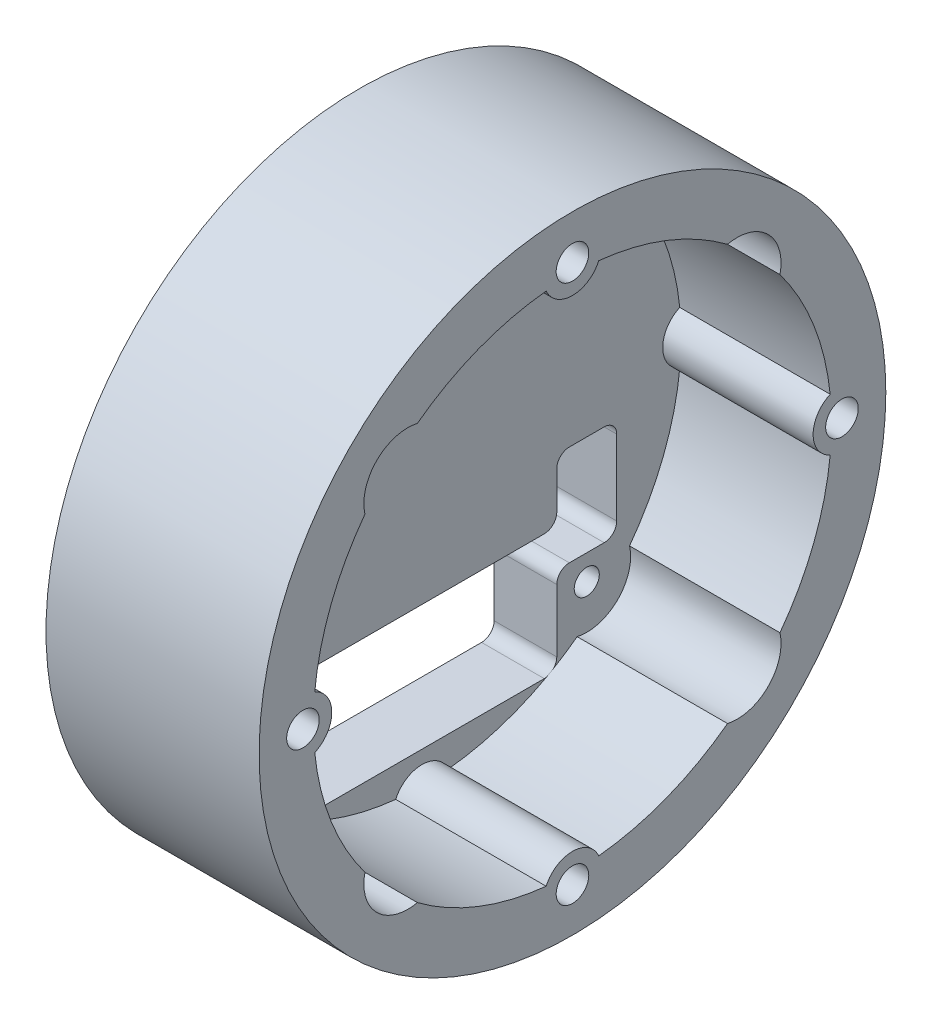
from build123d import *

# Parameters (mm, degrees)
SKETCH1_R               = 25
BOSS_EXTRUDE1_DEPTH     = 5
SKETCH3_R               = 1
CUT_EXTRUDE2_DEPTH      = 6
SKETCH4_R               = 25
SKETCH4_R_2             = 20.666666667
BOSS_EXTRUDE2_DEPTH     = 12
SKETCH2_R               = 1.3
CUT_EXTRUDE1_DEPTH      = 13
CUT_EXTRUDE1_DEPTH_BACK = 6
CUT_EXTRUDE3_DEPTH      = 6
CUT_EXTRUDE5_DEPTH      = 13
SKETCH8_R               = 2.3
SKETCH8_R_2             = 1.3
BOSS_EXTRUDE3_DEPTH     = 12


with BuildPart() as part:
    # Sketch1 → Boss-Extrude1 (new body)
    with BuildSketch(Plane(origin=(0, 0, 0), x_dir=(0, 0, -1), z_dir=(1, 0, 0))):
        Circle(SKETCH1_R)
    extrude(amount=BOSS_EXTRUDE1_DEPTH)

    # Sketch3 → Cut-Extrude2 (cut, through all)
    with BuildSketch(Plane.ZY):
        with Locations((-13.14, 13.14)):
            Circle(SKETCH3_R)
        with Locations((13.14, 13.14)):
            Circle(SKETCH3_R)
        with Locations((13.14, -13.14)):
            Circle(SKETCH3_R)
        with Locations((-13.14, -13.14)):
            Circle(SKETCH3_R)
    extrude(amount=-CUT_EXTRUDE2_DEPTH, mode=Mode.SUBTRACT)

    # Sketch4 → Boss-Extrude2 (add)
    with BuildSketch(Plane(origin=(5, 0, 0), x_dir=(0, 0, -1), z_dir=(1, 0, 0))):
        Circle(SKETCH4_R)
        Circle(SKETCH4_R_2, mode=Mode.SUBTRACT)
    extrude(amount=BOSS_EXTRUDE2_DEPTH)

    # Sketch2 → Cut-Extrude1 (cut, two sides)
    with BuildSketch(Plane(origin=(5, 0, 0), x_dir=(0, 0, -1), z_dir=(1, 0, 0))) as cut_extrude1_sk:
        with Locations((0, 21.5)):
            Circle(SKETCH2_R)
        with Locations((21.5, 0)):
            Circle(SKETCH2_R)
        with Locations((0, -21.5)):
            Circle(SKETCH2_R)
        with Locations((-21.5, 0)):
            Circle(SKETCH2_R)
    extrude(amount=CUT_EXTRUDE1_DEPTH, mode=Mode.SUBTRACT)
    extrude(cut_extrude1_sk.sketch, amount=-CUT_EXTRUDE1_DEPTH_BACK, mode=Mode.SUBTRACT)

    # Sketch5 → Cut-Extrude3 (cut, through all)
    with BuildSketch(Plane(origin=(5, 0, 0), x_dir=(0, 0, -1), z_dir=(1, 0, 0))):
        with BuildLine():
            Line((9.75, -8.14), (-9.75, -8.14))
            ThreePointArc((-9.75, -8.14), (-10.457106781, -8.432893219), (-10.75, -9.14))
            Line((-10.75, -9.14), (-10.75, -17.14))
            ThreePointArc((-10.75, -17.14), (-10.457106781, -17.847106781), (-9.75, -18.14))
            Line((-9.75, -18.14), (9.75, -18.14))
            ThreePointArc((9.75, -18.14), (10.457106781, -17.847106781), (10.75, -17.14))
            Line((10.75, -17.14), (10.75, -12.14))
            ThreePointArc((10.75, -12.14), (11.042893219, -11.432893219), (11.75, -11.14))
            Line((11.75, -11.14), (14.53, -11.14))
            ThreePointArc((14.53, -11.14), (15.237106781, -10.847106781), (15.53, -10.14))
            Line((15.53, -10.14), (15.53, -4.14))
            ThreePointArc((15.53, -4.14), (15.237106781, -3.432893219), (14.53, -3.14))
            Line((14.53, -3.14), (11.75, -3.14))
            ThreePointArc((11.75, -3.14), (11.042893219, -3.432893219), (10.75, -4.14))
            Line((10.75, -4.14), (10.75, -7.14))
            ThreePointArc((10.75, -7.14), (10.457106781, -7.847106781), (9.75, -8.14))
        make_face()
    extrude(amount=-CUT_EXTRUDE3_DEPTH, mode=Mode.SUBTRACT)

    # Sketch7 → Cut-Extrude5 (cut, through all)
    with BuildSketch(Plane(origin=(5, 0, 0), x_dir=(0, 0, -1), z_dir=(1, 0, 0))):
        with BuildLine():
            Line((-10.665126266, 15.614873734), (0, 4.949747468))
            Line((0, 4.949747468), (10.665126266, 15.614873734))
            ThreePointArc((10.665126266, 15.614873734), (15.614873734, 15.614873734), (15.614873734, 10.665126266))
            Line((15.614873734, 10.665126266), (4.949747468, 0))
            Line((4.949747468, 0), (15.614873734, -10.665126266))
            ThreePointArc((15.614873734, -10.665126266), (15.614873734, -15.614873734), (10.665126266, -15.614873734))
            Line((10.665126266, -15.614873734), (0, -4.949747468))
            Line((0, -4.949747468), (-10.665126266, -15.614873734))
            ThreePointArc((-10.665126266, -15.614873734), (-15.614873734, -15.614873734), (-15.614873734, -10.665126266))
            Line((-15.614873734, -10.665126266), (-4.949747468, 0))
            Line((-4.949747468, 0), (-15.614873734, 10.665126266))
            ThreePointArc((-15.614873734, 10.665126266), (-15.614873734, 15.614873734), (-10.665126266, 15.614873734))
        make_face()
    extrude(amount=CUT_EXTRUDE5_DEPTH, mode=Mode.SUBTRACT)

    # Sketch8 → Boss-Extrude3 (add)
    with BuildSketch(Plane(origin=(5, 0, 0), x_dir=(0, 0, -1), z_dir=(1, 0, 0))):
        with Locations((0, -21.5)):
            Circle(SKETCH8_R)
        with Locations((0, -21.5)):
            Circle(SKETCH8_R_2, mode=Mode.SUBTRACT)
        with Locations((-21.5, 0)):
            Circle(SKETCH8_R)
        with Locations((-21.5, 0)):
            Circle(SKETCH8_R_2, mode=Mode.SUBTRACT)
        with Locations((0, 21.5)):
            Circle(SKETCH8_R)
        with Locations((0, 21.5)):
            Circle(SKETCH8_R_2, mode=Mode.SUBTRACT)
        with Locations((21.5, 0)):
            Circle(SKETCH8_R)
        with Locations((21.5, 0)):
            Circle(SKETCH8_R_2, mode=Mode.SUBTRACT)
    extrude(amount=BOSS_EXTRUDE3_DEPTH)


solid = part.part
